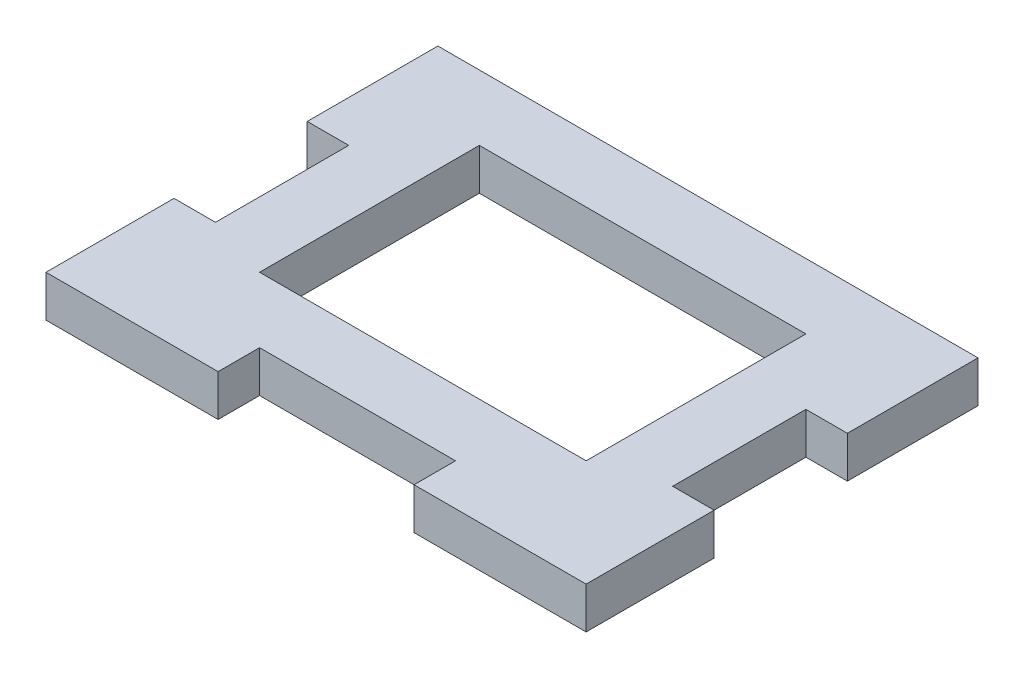
from build123d import *

# Parameters (mm, degrees)
SKETCH1_W               = 41.35
SKETCH1_H               = 30
BOSS_EXTRUDE1_DEPTH     = 3.175
SKETCH2_W               = 3.175
SKETCH2_H               = 10.2
SKETCH2_W_2             = 15
SKETCH2_H_2             = 3.175
CUT_EXTRUDE1_DEPTH      = 4.175
SKETCH3_W               = 25
SKETCH3_H               = 16.825
CUT_EXTRUDE2_DEPTH      = 1
CUT_EXTRUDE2_DEPTH_BACK = 4.175


with BuildPart() as part:
    # Sketch1 → Boss-Extrude1 (new body)
    with BuildSketch(Plane(origin=(0, 0, 0), x_dir=(1, 0, 0), z_dir=(0, 1, 0))):
        with Locations((20.675, 15)):
            Rectangle(SKETCH1_W, SKETCH1_H)
    extrude(amount=BOSS_EXTRUDE1_DEPTH)

    # Sketch2 → Cut-Extrude1 (cut, through all)
    with BuildSketch(Plane.XZ):
        with Locations((1.5875, -14.9)):
            Rectangle(SKETCH2_W, SKETCH2_H)
        with Locations((39.7625, -14.9)):
            Rectangle(SKETCH2_W, SKETCH2_H)
        with Locations((20.675, -1.5875)):
            Rectangle(SKETCH2_W_2, SKETCH2_H_2)
    extrude(amount=-CUT_EXTRUDE1_DEPTH, mode=Mode.SUBTRACT)

    # Sketch3 → Cut-Extrude2 (cut, two sides)
    with BuildSketch(Plane(origin=(0, 3.175, 0), x_dir=(1, 0, 0), z_dir=(0, 1, 0))) as cut_extrude2_sk:
        with Locations((20.675, 16.5875)):
            Rectangle(SKETCH3_W, SKETCH3_H)
    extrude(amount=CUT_EXTRUDE2_DEPTH, mode=Mode.SUBTRACT)
    extrude(cut_extrude2_sk.sketch, amount=-CUT_EXTRUDE2_DEPTH_BACK, mode=Mode.SUBTRACT)


solid = part.part
